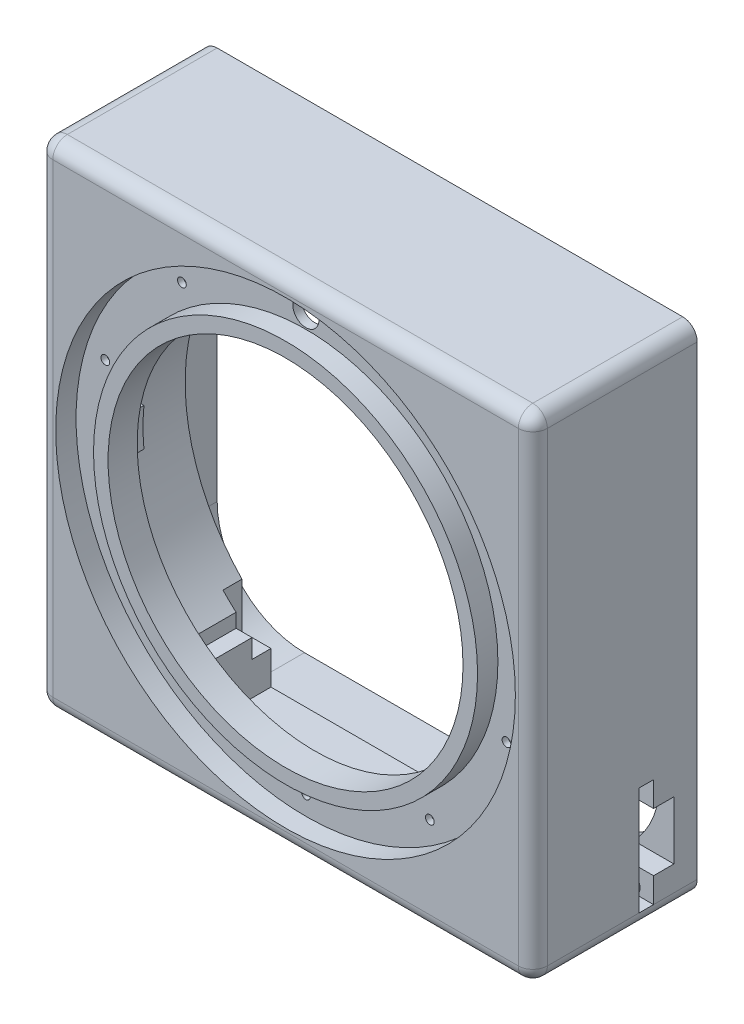
from build123d import *

# Parameters (mm, degrees)
ESQUISSE1_W                  = 85
ESQUISSE1_H                  = 85
BOSS_EXTRU_1_DEPTH           = 5
ESQUISSE2_R                  = 30.5
ENL_V_MAT_EXTRU_1_DEPTH      = 6
BOSS_EXTRU_2_DEPTH           = 3
ESQUISSE4_W                  = 85
ESQUISSE4_H                  = 85
BOSS_EXTRU_4_DEPTH           = 10
ESQUISSE5_W                  = 85
ESQUISSE5_H                  = 85
BOSS_EXTRU_5_DEPTH           = 3.25
ESQUISSE6_R                  = 39.5
ESQUISSE6_R_2                = 33
ENL_V_MAT_EXTRU_2_DEPTH      = 3.5
ESQUISSE7_R                  = 2.25
ENL_V_MAT_EXTRU_3_DEPTH      = 14.75
ESQUISSE8_W                  = 85
ESQUISSE8_H                  = 85
BOSS_EXTRU_6_DEPTH           = 10
CONG_1_R                     = 2.5
ESQUISSE9_W                  = 41.5
ESQUISSE9_H                  = 9
ENL_V_MAT_EXTRU_4_DEPTH      = 13.25
ESQUISSE10_R                 = 0.75
ENL_V_MAT_EXTRU_5_DEPTH      = 1
ESQUISSE11_R                 = 1.5
ENL_V_MAT_EXTRU_6_DEPTH      = 23.25
ENL_V_MAT_EXTRU_7_DEPTH      = 83.5
ENL_V_MAT_EXTRU_7_DEPTH_BACK = 3.5


with BuildPart() as part:
    # Esquisse1 → Boss.-Extru.1 (new body)
    with BuildSketch(Plane.XY):
        Rectangle(ESQUISSE1_W, ESQUISSE1_H)
    extrude(amount=BOSS_EXTRU_1_DEPTH)

    # Esquisse2 → Enlèv. mat.-Extru.1 (cut, through all)
    with BuildSketch(Plane.XY.offset(5)):
        Circle(ESQUISSE2_R)
    extrude(amount=-ENL_V_MAT_EXTRU_1_DEPTH, mode=Mode.SUBTRACT)

    # Esquisse3 → Boss.-Extru.2 (add)
    with BuildSketch(Plane(origin=(0, 0, 0), x_dir=(-1, 0, 0), z_dir=(0, 0, -1))):
        with BuildLine():
            Line((-32.337091706, 3.25), (-42.5, 3.25))
            Line((-42.5, 3.25), (-42.5, -3.25))
            Line((-42.5, -3.25), (-32.337091706, -3.25))
            ThreePointArc((-32.337091706, -3.25), (-32.5, 0), (-32.337091706, 3.25))
        make_face()
        with BuildLine():
            Line((32.337091706, -3.25), (42.5, -3.25))
            Line((42.5, -3.25), (42.5, 3.25))
            Line((42.5, 3.25), (32.337091706, 3.25))
            ThreePointArc((32.337091706, 3.25), (32.5, 0), (32.337091706, -3.25))
        make_face()
    extrude(amount=BOSS_EXTRU_2_DEPTH)

    # Esquisse4 → Boss.-Extru.4 (add)
    with BuildSketch(Plane(origin=(0, 0, 0), x_dir=(-1, 0, 0), z_dir=(0, 0, -1))):
        Rectangle(ESQUISSE4_W, ESQUISSE4_H)
        with BuildLine():
            Line((-23.5, 29), (-20.475595229, 29))
            ThreePointArc((-20.475595229, 29), (0, 35.5), (20.475595229, 29))
            Line((20.475595229, 29), (23.5, 29))
            Line((23.5, 29), (23.5, 26.608269391))
            ThreePointArc((23.5, 26.608269391), (32.996010976, 13.096307101), (35.350919366, -3.25))
            ThreePointArc((35.350919366, -3.25), (31.658488037, -16.062071324), (23.5, -26.608269391))
            Line((23.5, -26.608269391), (23.5, -29))
            Line((23.5, -29), (20.475595229, -29))
            ThreePointArc((20.475595229, -29), (0, -35.5), (-20.475595229, -29))
            Line((-20.475595229, -29), (-23.5, -29))
            Line((-23.5, -29), (-23.5, -26.608269391))
            ThreePointArc((-23.5, -26.608269391), (-31.658488037, -16.062071324), (-35.350919366, -3.25))
            ThreePointArc((-35.350919366, -3.25), (-32.996010976, 13.096307101), (-23.5, 26.608269391))
            Line((-23.5, 26.608269391), (-23.5, 29))
        make_face(mode=Mode.SUBTRACT)
    extrude(amount=BOSS_EXTRU_4_DEPTH)

    # Esquisse5 → Boss.-Extru.5 (add)
    with BuildSketch(Plane(origin=(0, 0, -10), x_dir=(-1, 0, 0), z_dir=(0, 0, -1))):
        Rectangle(ESQUISSE5_W, ESQUISSE5_H)
        with BuildLine():
            Line((14.838716252, 32.25), (25.75, 32.25))
            Line((25.75, 32.25), (25.75, 24.437420077))
            ThreePointArc((25.75, 24.437420077), (35.5, 0), (25.75, -24.437420077))
            Line((25.75, -24.437420077), (25.75, -32.25))
            Line((25.75, -32.25), (14.838716252, -32.25))
            ThreePointArc((14.838716252, -32.25), (0, -35.5), (-14.838716252, -32.25))
            Line((-14.838716252, -32.25), (-25.75, -32.25))
            Line((-25.75, -32.25), (-25.75, -24.437420077))
            ThreePointArc((-25.75, -24.437420077), (-35.5, 0), (-25.75, 24.437420077))
            Line((-25.75, 24.437420077), (-25.75, 32.25))
            Line((-25.75, 32.25), (-14.838716252, 32.25))
            ThreePointArc((-14.838716252, 32.25), (0, 35.5), (14.838716252, 32.25))
        make_face(mode=Mode.SUBTRACT)
    extrude(amount=BOSS_EXTRU_5_DEPTH)

    # Esquisse6 → Enlèv. mat.-Extru.2 (cut)
    with BuildSketch(Plane.XY.offset(5)):
        Circle(ESQUISSE6_R)
        Circle(ESQUISSE6_R_2, mode=Mode.SUBTRACT)
    extrude(amount=-ENL_V_MAT_EXTRU_2_DEPTH, mode=Mode.SUBTRACT)

    # Esquisse7 → Enlèv. mat.-Extru.3 (cut)
    with BuildSketch(Plane(origin=(0, 0, -13.25), x_dir=(-1, 0, 0), z_dir=(0, 0, -1))):
        with Locations((0, 35.5)):
            Circle(ESQUISSE7_R)
    extrude(amount=-ENL_V_MAT_EXTRU_3_DEPTH, mode=Mode.SUBTRACT)

    # Esquisse8 → Boss.-Extru.6 (add)
    with BuildSketch(Plane(origin=(0, 0, -13.25), x_dir=(-1, 0, 0), z_dir=(0, 0, -1))):
        Rectangle(ESQUISSE8_W, ESQUISSE8_H)
        with BuildLine():
            Line((-25, 40), (25, 40))
            ThreePointArc((25, 40), (35.606601718, 35.606601718), (40, 25))
            Line((40, 25), (40, -25))
            ThreePointArc((40, -25), (35.606601718, -35.606601718), (25, -40))
            Line((25, -40), (-25, -40))
            ThreePointArc((-25, -40), (-35.606601718, -35.606601718), (-40, -25))
            Line((-40, -25), (-40, 25))
            ThreePointArc((-40, 25), (-35.606601718, 35.606601718), (-25, 40))
        make_face(mode=Mode.SUBTRACT)
    extrude(amount=BOSS_EXTRU_6_DEPTH)

    # Congé1
    cong_1_edges = [part.edges().sort_by_distance(p)[0] for p in [
        (-42.5, 0, 5),
        (0, -42.5, 5),
        (42.5, 0, 5),
        (42.5, -42.5, -9.125),
        (-42.5, -42.5, -9.125),
        (-42.5, 42.5, -9.125),
        (42.5, 42.5, -9.125),
        (0, 42.5, 5),
    ]]
    fillet(cong_1_edges, radius=CONG_1_R)

    # Esquisse9 → Enlèv. mat.-Extru.4 (cut)
    with BuildSketch(Plane(origin=(0, 0, -13.25), x_dir=(-1, 0, 0), z_dir=(0, 0, -1))):
        with Locations((0, -33.5)):
            Rectangle(ESQUISSE9_W, ESQUISSE9_H)
    extrude(amount=-ENL_V_MAT_EXTRU_4_DEPTH, mode=Mode.SUBTRACT)

    # Esquisse10 → Enlèv. mat.-Extru.5 (cut)
    with BuildSketch(Plane.XY.offset(1.5)):
        with Locations((0, 36.25)):
            Circle(ESQUISSE10_R)
        with Locations((21.307215396, 29.326866046)):
            Circle(ESQUISSE10_R)
        with Locations((34.475798716, 11.201866046)):
            Circle(ESQUISSE10_R)
        with Locations((34.475798716, -11.201866046)):
            Circle(ESQUISSE10_R)
        with Locations((21.307215396, -29.326866046)):
            Circle(ESQUISSE10_R)
        with Locations((0, -36.25)):
            Circle(ESQUISSE10_R)
        with Locations((-21.307215396, -29.326866046)):
            Circle(ESQUISSE10_R)
        with Locations((-34.475798716, -11.201866046)):
            Circle(ESQUISSE10_R)
        with Locations((-34.475798716, 11.201866046)):
            Circle(ESQUISSE10_R)
        with Locations((-21.307215396, 29.326866046)):
            Circle(ESQUISSE10_R)
    extrude(amount=-ENL_V_MAT_EXTRU_5_DEPTH, mode=Mode.SUBTRACT)

    # Esquisse11 → Enlèv. mat.-Extru.6 (cut)
    with BuildSketch(Plane(origin=(0, 0, -23.25), x_dir=(-1, 0, 0), z_dir=(0, 0, -1))):
        with Locations((38.687184335, 38.687184335)):
            Circle(ESQUISSE11_R)
        with Locations((38.687184335, -38.687184335)):
            Circle(ESQUISSE11_R)
        with Locations((-38.687184335, -38.687184335)):
            Circle(ESQUISSE11_R)
        with Locations((-38.687184335, 38.687184335)):
            Circle(ESQUISSE11_R)
    extrude(amount=-ENL_V_MAT_EXTRU_6_DEPTH, mode=Mode.SUBTRACT)

    # Esquisse12 → Enlèv. mat.-Extru.7 (cut, two sides)
    with BuildSketch(Plane.ZY.offset(-40)) as enl_v_mat_extru_7_sk:
        Polygon((-13.25, -21.4), (-15.75, -21.4), (-15.75, -25.7), (-19.25, -25.7), (-19.25, -35.7), (-15.75, -35.7), (-15.75, -40), (-13.25, -40), align=None)
    extrude(amount=ENL_V_MAT_EXTRU_7_DEPTH, mode=Mode.SUBTRACT)
    extrude(enl_v_mat_extru_7_sk.sketch, amount=-ENL_V_MAT_EXTRU_7_DEPTH_BACK, mode=Mode.SUBTRACT)


solid = part.part
